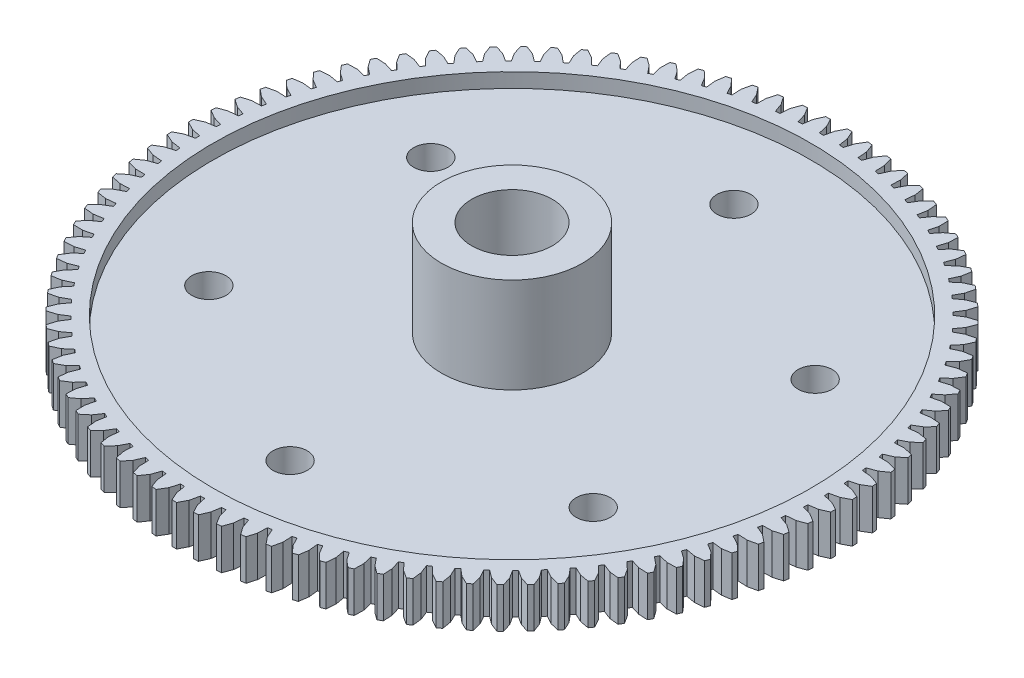
from build123d import *

# Parameters (mm, degrees)
SKETCH1_R           = 25.9334
BOSS_EXTRUDE1_DEPTH = 3.175
SKETCH2_R           = 5.5499
BOSS_EXTRUDE2_DEPTH = 6.35
SKETCH3_R           = 3.175
CUT_EXTRUDE1_DEPTH  = 10.525
SKETCH4_R           = 23.5204
SKETCH4_R_2         = 5.5499
CUT_EXTRUDE2_DEPTH  = 1.143
SKETCH5_R           = 1.3462
CUT_EXTRUDE3_DEPTH  = 4.175
CIRPATTERN1_COUNT   = 6
CUT_EXTRUDE4_DEPTH  = 4.175
CIRPATTERN2_COUNT   = 96


with BuildPart() as part:
    # Sketch1 → Boss-Extrude1 (new body)
    with BuildSketch(Plane(origin=(0, 0, 0), x_dir=(1, 0, 0), z_dir=(0, 1, 0))):
        Circle(SKETCH1_R)
    extrude(amount=BOSS_EXTRUDE1_DEPTH)

    # Sketch2 → Boss-Extrude2 (add)
    with BuildSketch(Plane(origin=(0, 3.175, 0), x_dir=(1, 0, 0), z_dir=(0, 1, 0))):
        Circle(SKETCH2_R)
    extrude(amount=BOSS_EXTRUDE2_DEPTH)

    # Sketch3 → Cut-Extrude1 (cut, through all)
    with BuildSketch(Plane(origin=(0, 9.525, 0), x_dir=(1, 0, 0), z_dir=(0, 1, 0))):
        Circle(SKETCH3_R)
    extrude(amount=-CUT_EXTRUDE1_DEPTH, mode=Mode.SUBTRACT)

    # Sketch4 → Cut-Extrude2 (cut)
    with BuildSketch(Plane(origin=(0, 3.175, 0), x_dir=(1, 0, 0), z_dir=(0, 1, 0))):
        Circle(SKETCH4_R)
        Circle(SKETCH4_R_2, mode=Mode.SUBTRACT)
    extrude(amount=-CUT_EXTRUDE2_DEPTH, mode=Mode.SUBTRACT)

    # Sketch5 → Cut-Extrude3 (cut, through all)
    with BuildSketch(Plane(origin=(0, 3.175, 0), x_dir=(1, 0, 0), z_dir=(0, 1, 0))):
        with Locations((0, 17.4625)):
            Circle(SKETCH5_R)
    cut_extrude3 = extrude(amount=-CUT_EXTRUDE3_DEPTH, mode=Mode.SUBTRACT)

    # CirPattern1: Cut-Extrude3 ×6 about axis
    cirpattern1_axis = Axis((0, 0, 0), (0, 1, 0))
    for i in range(1, CIRPATTERN1_COUNT):
        add(cut_extrude3.rotate(cirpattern1_axis, i * 360 / CIRPATTERN1_COUNT), mode=Mode.SUBTRACT)

    # Sketch6 → Cut-Extrude4 (cut, through all)
    with BuildSketch(Plane(origin=(0, 3.175, 0), x_dir=(1, 0, 0), z_dir=(0, 1, 0))):
        Polygon((-59.39647831, 138.372032762), (-0.864630885, 25.9334), (-0.521377679, 25.274016728), (-0.360481492, 24.548260928), (-0.033415885, 24.548260928), (0.127480302, 25.274016728), (0.470733508, 25.9334), (59.002580932, 138.372032762), (59.002580932, 391.894602173), (-59.39647831, 391.894602173), align=None)
    cut_extrude4 = extrude(amount=-CUT_EXTRUDE4_DEPTH, mode=Mode.SUBTRACT)

    # CirPattern2: Cut-Extrude4 ×96 about axis
    cirpattern2_axis = Axis((0, 3.175, 0), (0, -1, 0))
    for i in range(1, CIRPATTERN2_COUNT):
        add(cut_extrude4.rotate(cirpattern2_axis, i * 360 / CIRPATTERN2_COUNT), mode=Mode.SUBTRACT)


solid = part.part
